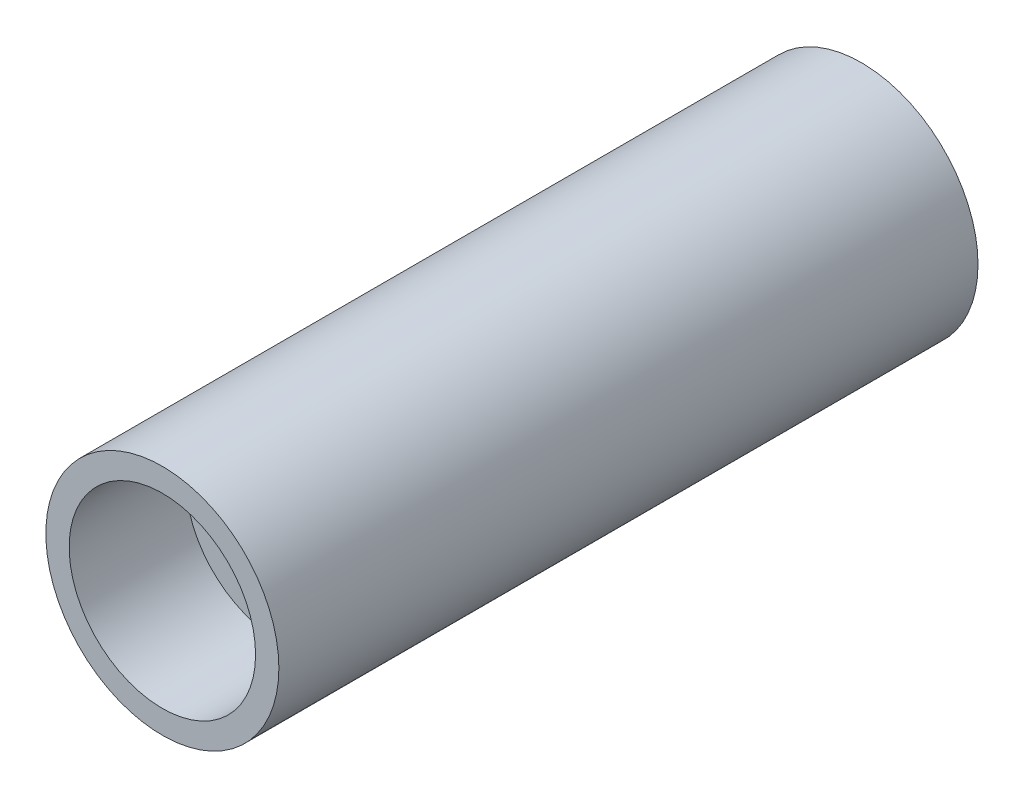
from build123d import *

# Parameters (mm, degrees)
SKETCH1_R           = 5
BOSS_EXTRUDE1_DEPTH = 30
SKETCH2_R           = 4
CUT_EXTRUDE1_DEPTH  = 5


with BuildPart() as part:
    # Sketch1 → Boss-Extrude1 (new body)
    with BuildSketch(Plane.XY):
        Circle(SKETCH1_R)
    extrude(amount=BOSS_EXTRUDE1_DEPTH)

    # Sketch2 → Cut-Extrude1 (cut)
    with BuildSketch(Plane.XY.offset(30)):
        Circle(SKETCH2_R)
    extrude(amount=-CUT_EXTRUDE1_DEPTH, mode=Mode.SUBTRACT)


solid = part.part
